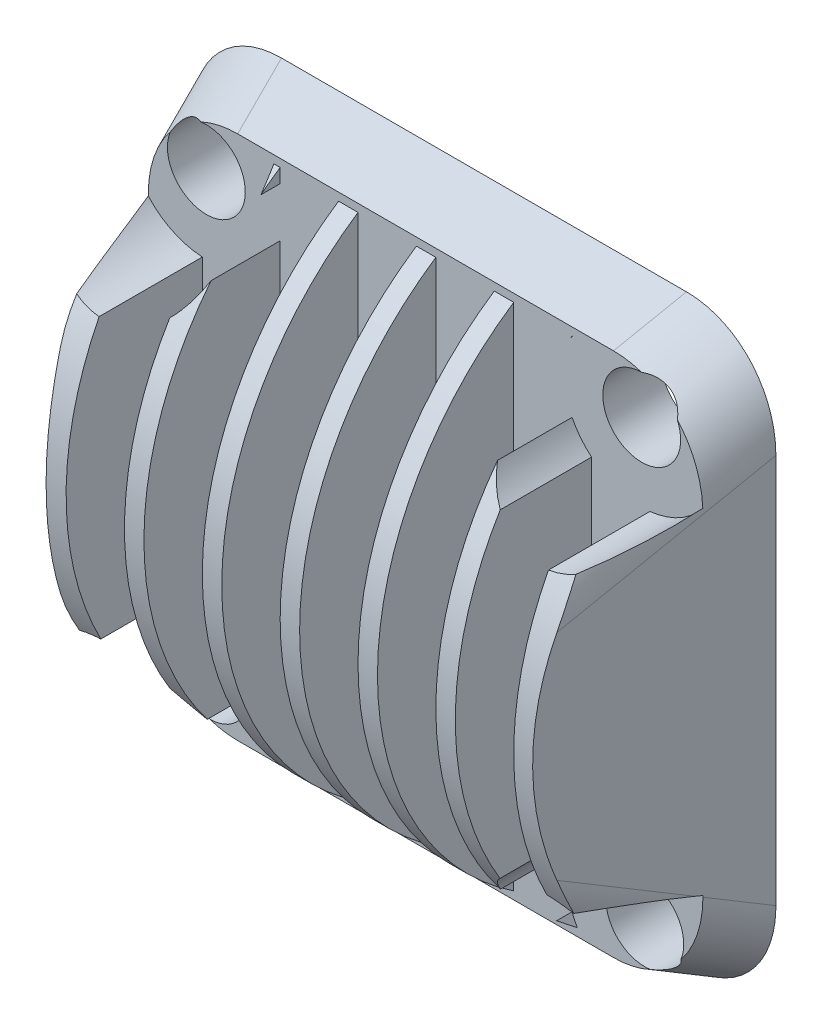
from build123d import *

# Parameters (mm, degrees)
SKETCH2_W               = 25
SKETCH2_H               = 20
SKETCH1_W               = 30
SKETCH1_H               = 30
FILLET1_R               = 5
SKETCH3_W               = 3
SKETCH3_H               = 9.426867849
CUT_EXTRUDE1_DEPTH      = 16.0000001
LPATTERN3_COUNT         = 6
LPATTERN3_PITCH         = 4
CUT_EXTRUDE4_DEPTH      = 16.0000001
CUT_EXTRUDE4_DEPTH_BACK = 16.0000001
CUT_EXTRUDE5_START      = -11.0000001
SKETCH5_R               = 2
CUT_EXTRUDE5_DEPTH      = 12.0000002
SKETCH6_R               = 12.5
CUT_EXTRUDE6_DEPTH      = 1
SKETCH9_R               = 4
CUT_EXTRUDE9_DEPTH      = 14
CIRPATTERN2_COUNT       = 4


with BuildPart() as part:
    # Sketch2 → Loft1 section 0
    with BuildSketch(Plane.XY.offset(10)):
        Rectangle(SKETCH2_W, SKETCH2_H)
    # Sketch1 → Loft1 section 1
    with BuildSketch(Plane.XY):
        Rectangle(SKETCH1_W, SKETCH1_H)
    loft()

    # Fillet1
    fillet1_edges = [part.edges().sort_by_distance(p)[0] for p in [
        (-13.75, 12.5, 5),
        (13.75, 12.5, 5),
        (13.75, -12.5, 5),
        (-13.75, -12.5, 5),
    ]]
    fillet(fillet1_edges, radius=FILLET1_R)

    # Sketch3 → Cut-Extrude1 (cut, symmetric)
    with BuildSketch(Plane(origin=(0, 0, 0), x_dir=(1, 0, 0), z_dir=(0, 1, 0))):
        with Locations((-9.9726291, -7.713433925)):
            Rectangle(SKETCH3_W, SKETCH3_H)
    cut_extrude1 = extrude(amount=CUT_EXTRUDE1_DEPTH, both=True, mode=Mode.SUBTRACT)

    # LPattern3: Cut-Extrude1 ×6
    with Locations(*[(i * LPATTERN3_PITCH, 0, 0) for i in range(1, LPATTERN3_COUNT)]):
        add(cut_extrude1, mode=Mode.SUBTRACT)

    # Sketch4 → Cut-Extrude4 (cut, two sides)
    with BuildSketch(Plane(origin=(0, 0, 0), x_dir=(0, 0, -1), z_dir=(1, 0, 0))) as cut_extrude4_sk:
        with BuildLine():
            Line((-3, 13.095865845), (-3, 16.032991948))
            Line((-3, 16.032991948), (-15.060331803, 16.032991948))
            Line((-15.060331803, 16.032991948), (-15.060331803, -14.592776026))
            Line((-15.060331803, -14.592776026), (-3, -14.592776026))
            Line((-3, -14.592776026), (-3, -13.095865845))
            ThreePointArc((-3, -13.095865845), (-10, 0), (-3, 13.095865845))
        make_face()
    extrude(amount=CUT_EXTRUDE4_DEPTH, mode=Mode.SUBTRACT)
    extrude(cut_extrude4_sk.sketch, amount=-CUT_EXTRUDE4_DEPTH_BACK, mode=Mode.SUBTRACT)

    # Sketch5 → Cut-Extrude5 (cut)
    with BuildSketch(Plane(origin=(0, 0, 0), x_dir=(-1, 0, 0), z_dir=(0, 0, -1)).offset(CUT_EXTRUDE5_START)):
        with Locations((-11.105145919, 11.265282272)):
            Circle(SKETCH5_R)
    cut_extrude5 = extrude(amount=CUT_EXTRUDE5_DEPTH, mode=Mode.SUBTRACT)

    # Sketch6 → Cut-Extrude6 (cut)
    with BuildSketch(Plane(origin=(0, 0, 0), x_dir=(-1, 0, 0), z_dir=(0, 0, -1))):
        Circle(SKETCH6_R)
    extrude(amount=-CUT_EXTRUDE6_DEPTH, mode=Mode.SUBTRACT)

    # Sketch9 → Cut-Extrude9 (cut)
    with BuildSketch(Plane.XY.offset(3)):
        with Locations((11.105145919, 11.265282272)):
            Circle(SKETCH9_R)
    cut_extrude9 = extrude(amount=CUT_EXTRUDE9_DEPTH, mode=Mode.SUBTRACT)

    # CirPattern2: Cut-Extrude5, Cut-Extrude9 ×4 about axis
    cirpattern2_axis = Axis((0, 0, 0), (0, 0, 1))
    for i in range(1, CIRPATTERN2_COUNT):
        add(cut_extrude5.rotate(cirpattern2_axis, i * 360 / CIRPATTERN2_COUNT), mode=Mode.SUBTRACT)
        add(cut_extrude9.rotate(cirpattern2_axis, i * 360 / CIRPATTERN2_COUNT), mode=Mode.SUBTRACT)


solid = part.part
